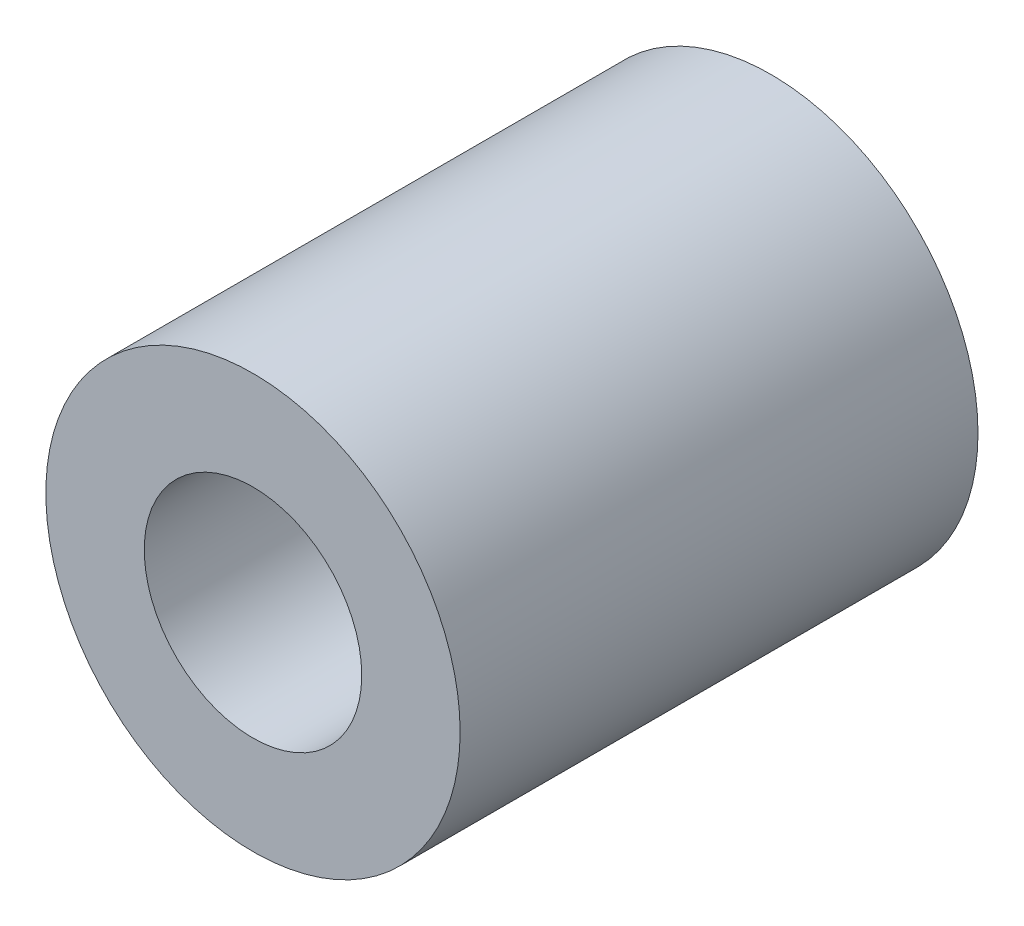
from build123d import *

# Parameters (mm, degrees)
SKETCH1_R           = 4
SKETCH1_R_2         = 2.1
EXTRUDE1_DEPTH      = 5
EXTRUDE1_DEPTH_BACK = 5


with BuildPart() as part:
    # Sketch1 → Extrude1 (new body, two sides)
    with BuildSketch(Plane.XY) as extrude1_sk:
        Circle(SKETCH1_R)
        Circle(SKETCH1_R_2, mode=Mode.SUBTRACT)
    extrude(amount=EXTRUDE1_DEPTH)
    extrude(extrude1_sk.sketch, amount=-EXTRUDE1_DEPTH_BACK)


solid = part.part
